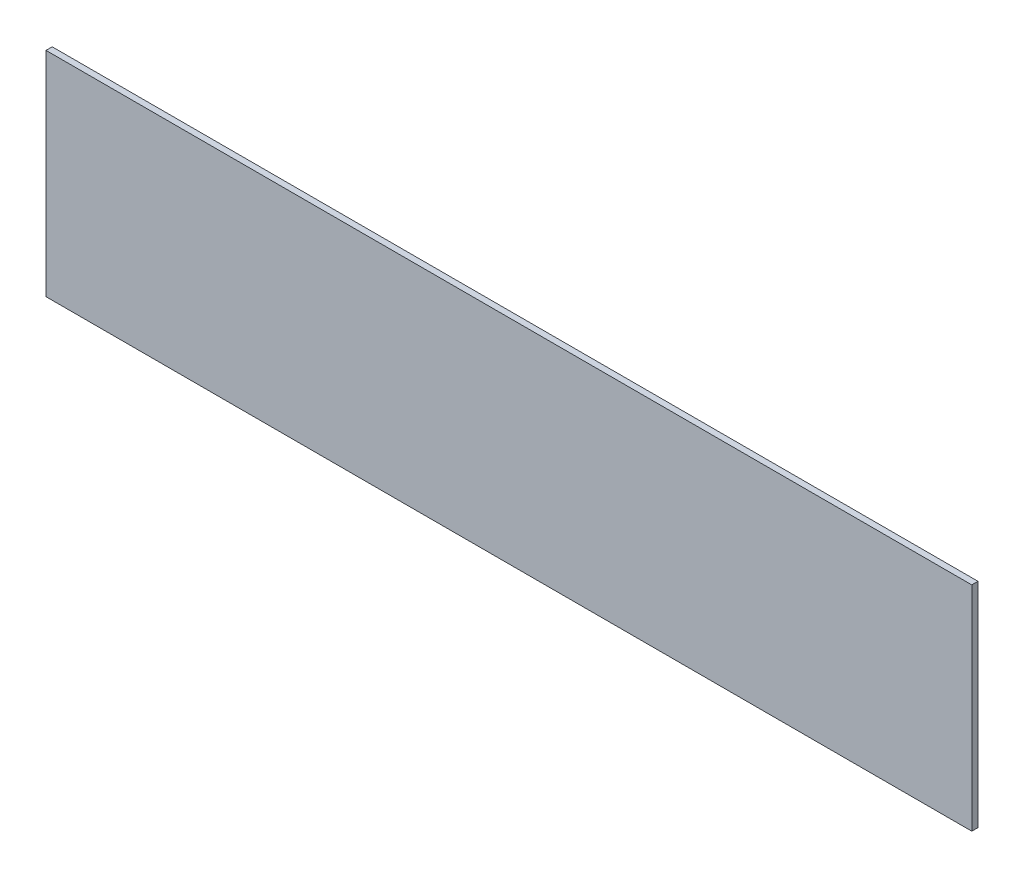
from build123d import *

# Parameters (mm, degrees)
SKETCH1_W           = 450
SKETCH1_H           = 103
BOSS_EXTRUDE1_DEPTH = 3
SKETCH7_W           = 3
SKETCH7_H           = 103
CUT_EXTRUDE5_DEPTH  = 10


with BuildPart() as part:
    # Sketch1 → Boss-Extrude1 (new body)
    with BuildSketch(Plane.XY):
        with Locations((225, 51.5)):
            Rectangle(SKETCH1_W, SKETCH1_H)
    extrude(amount=BOSS_EXTRUDE1_DEPTH)

    # Sketch7 → Cut-Extrude5 (cut)
    with BuildSketch(Plane(origin=(0, 0, 0), x_dir=(-1, 0, 0), z_dir=(0, 0, -1))):
        with Locations((-1.5, 51.5)):
            Rectangle(SKETCH7_W, SKETCH7_H)
    extrude(amount=-CUT_EXTRUDE5_DEPTH, mode=Mode.SUBTRACT)


solid = part.part
